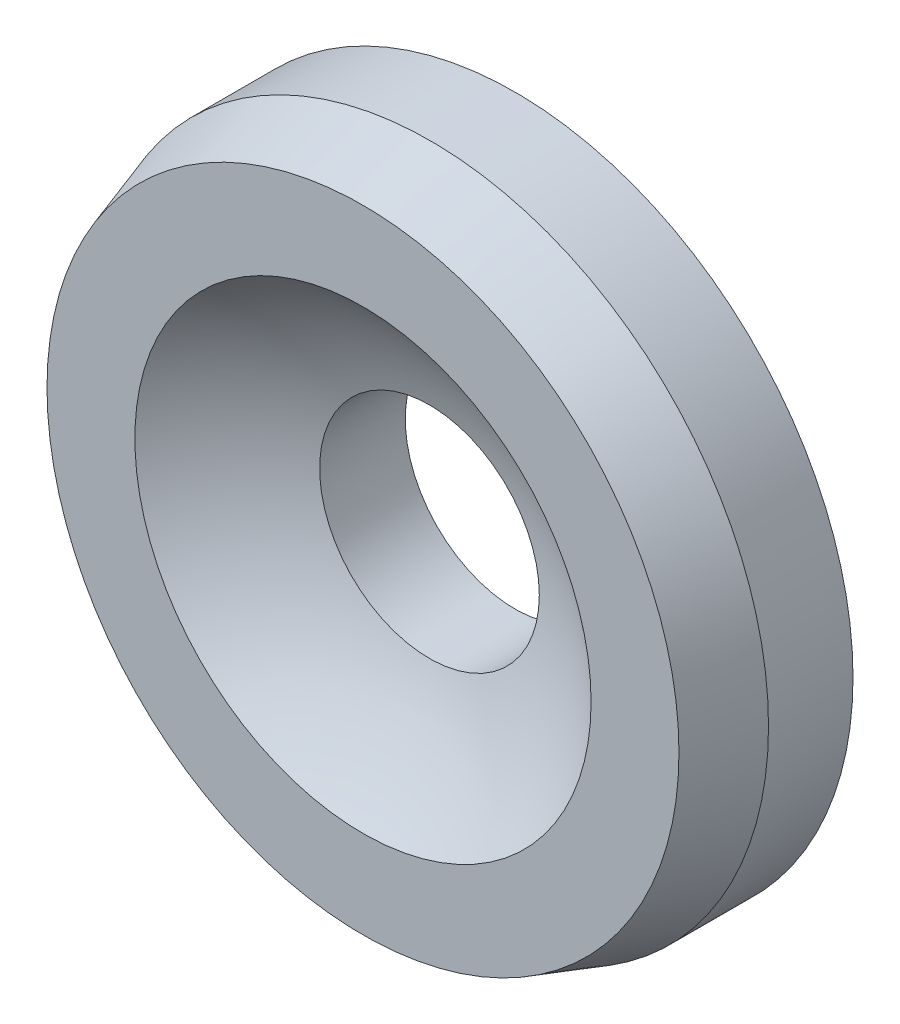
from build123d import *


with BuildPart() as part:
    # Sketch1 → Revolve1 (revolve)
    with BuildSketch(Plane(origin=(0, -6.0740848, 0), x_dir=(1, 0, 0), z_dir=(0, 1, 0))):
        with BuildLine():
            Line((-1.662261998, -1.57), (-1.662261998, -1.32))
            Line((-1.662261998, -1.32), (-2.337261998, -1.32))
            Line((-2.337261998, -1.32), (-2.337261998, -1.573271349))
            ThreePointArc((-2.337261998, -1.573271349), (-2.152678305, -1.654585323), (-1.987261998, -1.77))
            Line((-1.987261998, -1.77), (-1.727245938, -1.77))
            Line((-1.727245938, -1.77), (-1.662261998, -1.57))
        make_face()
    revolve(axis=Axis((-2.662261998, -6.0740848, 1.32), (0, 0, 1)))


solid = part.part
